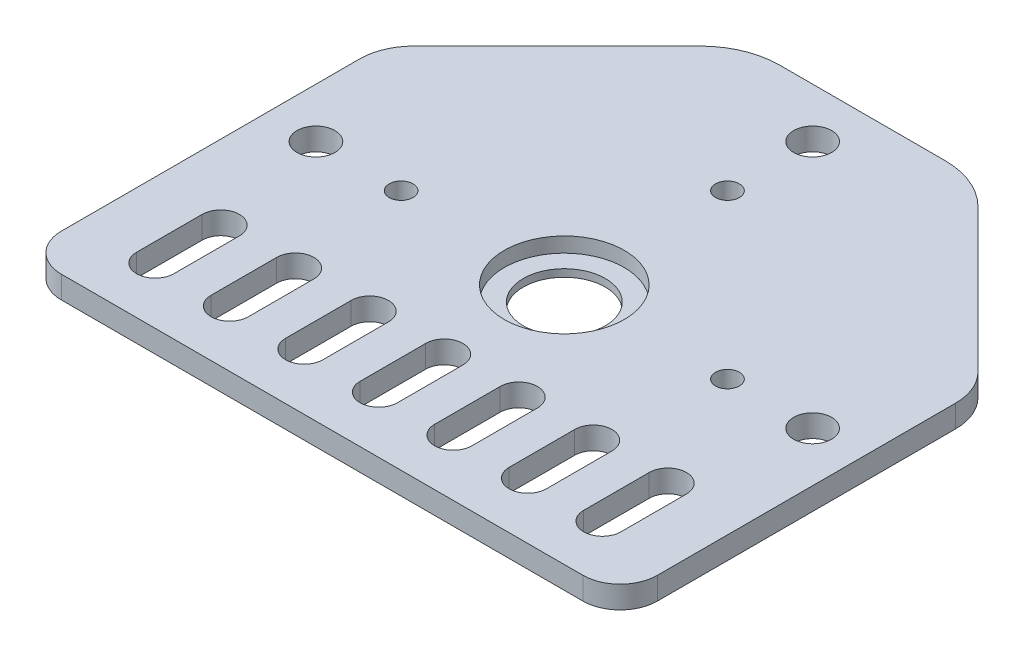
from build123d import *

# Parameters (mm, degrees)
SKETCH1_R           = 5.5
SKETCH1_R_2         = 2.55
SKETCH1_R_3         = 1.6
BOSS_EXTRUDE1_DEPTH = 3
SKETCH2_R           = 8.05
CUT_EXTRUDE1_DEPTH  = 2


with BuildPart() as part:
    # Sketch1 → Boss-Extrude1 (new body)
    with BuildSketch(Plane(origin=(0, 0, 0), x_dir=(1, 0, 0), z_dir=(0, 1, 0))):
        with BuildLine():
            Line((-37.861879503, 50.161879503), (-18.657716447, 69.366042559))
            ThreePointArc((-18.657716447, 69.366042559), (-15.186386614, 71.685510998), (-11.091673888, 72.5))
            Line((-11.091673888, 72.5), (11.091673888, 72.5))
            ThreePointArc((11.091673888, 72.5), (15.186386614, 71.685510998), (18.657716447, 69.366042559))
            Line((18.657716447, 69.366042559), (37.861879503, 50.161879503))
            ThreePointArc((37.861879503, 50.161879503), (39.444320587, 47.793589056), (40, 45))
            Line((40, 45), (40, 5))
            ThreePointArc((40, 5), (38.535533906, 1.464466094), (35, 0))
            Line((35, 0), (-35, 0))
            ThreePointArc((-35, 0), (-38.535533906, 1.464466094), (-40, 5))
            Line((-40, 5), (-40, 45))
            ThreePointArc((-40, 45), (-39.444320587, 47.793589056), (-37.861879503, 50.161879503))
        make_face()
        with Locations((0, 32.5)):
            Circle(SKETCH1_R, mode=Mode.SUBTRACT)
        with Locations((0, 65.83)):
            Circle(SKETCH1_R_2, mode=Mode.SUBTRACT)
        with Locations((0, 54.4)):
            Circle(SKETCH1_R_3, mode=Mode.SUBTRACT)
        with Locations((-33.33, 32.5)):
            Circle(SKETCH1_R_2, mode=Mode.SUBTRACT)
        with Locations((-21.9, 32.5)):
            Circle(SKETCH1_R_3, mode=Mode.SUBTRACT)
        with Locations((33.33, 32.5)):
            Circle(SKETCH1_R_2, mode=Mode.SUBTRACT)
        with Locations((21.9, 32.5)):
            Circle(SKETCH1_R_3, mode=Mode.SUBTRACT)
        with BuildLine():
            Line((-2.5, 7.6), (-2.5, 16.4))
            ThreePointArc((-2.5, 16.4), (0, 18.9), (2.5, 16.4))
            Line((2.5, 16.4), (2.5, 7.6))
            ThreePointArc((2.5, 7.6), (0, 5.1), (-2.5, 7.6))
        make_face(mode=Mode.SUBTRACT)
        with BuildLine():
            Line((7.5, 7.6), (7.5, 16.4))
            ThreePointArc((7.5, 16.4), (10, 18.9), (12.5, 16.4))
            Line((12.5, 16.4), (12.5, 7.6))
            ThreePointArc((12.5, 7.6), (10, 5.1), (7.5, 7.6))
        make_face(mode=Mode.SUBTRACT)
        with BuildLine():
            Line((17.5, 7.6), (17.5, 16.4))
            ThreePointArc((17.5, 16.4), (20, 18.9), (22.5, 16.4))
            Line((22.5, 16.4), (22.5, 7.6))
            ThreePointArc((22.5, 7.6), (20, 5.1), (17.5, 7.6))
        make_face(mode=Mode.SUBTRACT)
        with BuildLine():
            Line((27.5, 7.6), (27.5, 16.4))
            ThreePointArc((27.5, 16.4), (30, 18.9), (32.5, 16.4))
            Line((32.5, 16.4), (32.5, 7.6))
            ThreePointArc((32.5, 7.6), (30, 5.1), (27.5, 7.6))
        make_face(mode=Mode.SUBTRACT)
        with BuildLine():
            Line((-7.5, 7.6), (-7.5, 16.4))
            ThreePointArc((-7.5, 16.4), (-10, 18.9), (-12.5, 16.4))
            Line((-12.5, 16.4), (-12.5, 7.6))
            ThreePointArc((-12.5, 7.6), (-10, 5.1), (-7.5, 7.6))
        make_face(mode=Mode.SUBTRACT)
        with BuildLine():
            Line((-17.5, 7.6), (-17.5, 16.4))
            ThreePointArc((-17.5, 16.4), (-20, 18.9), (-22.5, 16.4))
            Line((-22.5, 16.4), (-22.5, 7.6))
            ThreePointArc((-22.5, 7.6), (-20, 5.1), (-17.5, 7.6))
        make_face(mode=Mode.SUBTRACT)
        with BuildLine():
            Line((-27.5, 7.6), (-27.5, 16.4))
            ThreePointArc((-27.5, 16.4), (-30, 18.9), (-32.5, 16.4))
            Line((-32.5, 16.4), (-32.5, 7.6))
            ThreePointArc((-32.5, 7.6), (-30, 5.1), (-27.5, 7.6))
        make_face(mode=Mode.SUBTRACT)
    extrude(amount=BOSS_EXTRUDE1_DEPTH)

    # Sketch2 → Cut-Extrude1 (cut)
    with BuildSketch(Plane(origin=(0, 3, 0), x_dir=(1, 0, 0), z_dir=(0, 1, 0))):
        with Locations((0, 32.5)):
            Circle(SKETCH2_R)
    extrude(amount=-CUT_EXTRUDE1_DEPTH, mode=Mode.SUBTRACT)


solid = part.part
